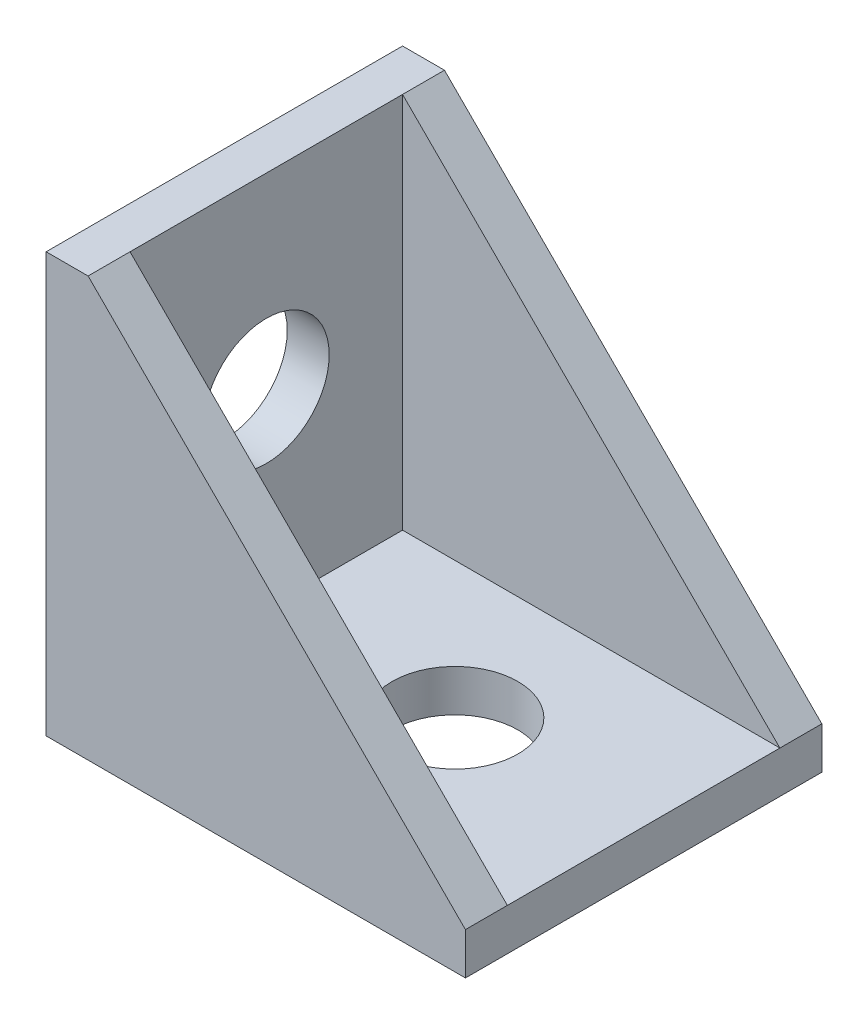
from build123d import *

# Parameters (mm, degrees)
RESSALTO_EXTRUS_O1_DEPTH = 17
ESBO_O2_W                = 18
ESBO_O2_H                = 13
CORTE_EXTRUS_O1_DEPTH    = 18
ESBO_O3_R                = 3
CORTE_EXTRUS_O2_DEPTH    = 2
ESBO_O4_R                = 3
CORTE_EXTRUS_O3_DEPTH    = 3


with BuildPart() as part:
    # Esboço1 → Ressalto-extrusão1 (new body)
    with BuildSketch(Plane.XY):
        Polygon((0, 0), (0, 20), (2, 20), (20, 2), (20, 0), align=None)
    extrude(amount=RESSALTO_EXTRUS_O1_DEPTH)

    # Esboço2 → Corte-extrusão1 (cut)
    with BuildSketch(Plane(origin=(0, 20, 0), x_dir=(1, 0, 0), z_dir=(0, 1, 0))):
        with Locations((11, -8.5)):
            Rectangle(ESBO_O2_W, ESBO_O2_H)
    extrude(amount=-CORTE_EXTRUS_O1_DEPTH, mode=Mode.SUBTRACT)

    # Esboço3 → Corte-extrusão2 (cut)
    with BuildSketch(Plane(origin=(2, 0, 0), x_dir=(0, 0, -1), z_dir=(1, 0, 0))):
        with Locations((-8.5, 11)):
            Circle(ESBO_O3_R)
    extrude(amount=-CORTE_EXTRUS_O2_DEPTH, mode=Mode.SUBTRACT)

    # Esboço4 → Corte-extrusão3 (cut, through all)
    with BuildSketch(Plane(origin=(0, 2, 0), x_dir=(1, 0, 0), z_dir=(0, 1, 0))):
        with Locations((11, -8.5)):
            Circle(ESBO_O4_R)
    extrude(amount=-CORTE_EXTRUS_O3_DEPTH, mode=Mode.SUBTRACT)


solid = part.part
